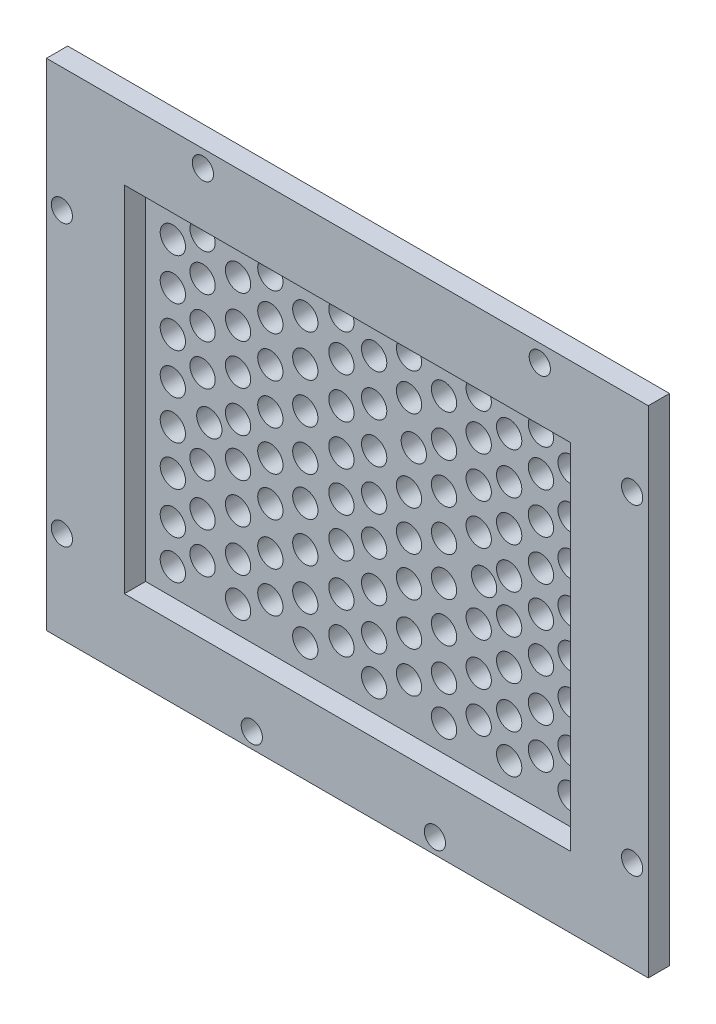
from build123d import *

# Parameters (mm, degrees)
SKETCH1_W                       = 85
SKETCH1_H                       = 70
BOSS_EXTRUDE1_DEPTH             = 6
SKETCH2_W                       = 76
SKETCH2_H                       = 61
SKETCH2_W_2                     = 65
SKETCH2_H_2                     = 52.171052632
CUT_EXTRUDE1_DEPTH              = 5
SKETCH8_W                       = 63
SKETCH8_H                       = 50
CUT_EXTRUDE2_DEPTH              = 3
SKETCH19_W                      = 85
SKETCH19_H                      = 70
SKETCH19_W_2                    = 76
SKETCH19_H_2                    = 61
CUT_EXTRUDE3_DEPTH              = 3
F_9_64_0_14063_DIAMETER_HOLE3_D = 3.572002
F_3_0MM_DOWEL_HOLE1_D           = 3
F_3_0MM_DOWEL_HOLE1_DEPTH       = 3


with BuildPart() as part:
    # Sketch1 → Boss-Extrude1 (new body)
    with BuildSketch(Plane.XY):
        Rectangle(SKETCH1_W, SKETCH1_H)
    extrude(amount=BOSS_EXTRUDE1_DEPTH)

    # Sketch2 → Cut-Extrude1 (cut)
    with BuildSketch(Plane(origin=(0, 0, 0), x_dir=(-1, 0, 0), z_dir=(0, 0, -1))):
        Rectangle(SKETCH2_W, SKETCH2_H)
        Rectangle(SKETCH2_W_2, SKETCH2_H_2, mode=Mode.SUBTRACT)
    extrude(amount=-CUT_EXTRUDE1_DEPTH, mode=Mode.SUBTRACT)

    # Sketch8 → Cut-Extrude2 (cut)
    with BuildSketch(Plane.XY.offset(6)):
        Rectangle(SKETCH8_W, SKETCH8_H)
    extrude(amount=-CUT_EXTRUDE2_DEPTH, mode=Mode.SUBTRACT)

    # Sketch19 → Cut-Extrude3 (cut)
    with BuildSketch(Plane(origin=(0, 0, 0), x_dir=(-1, 0, 0), z_dir=(0, 0, -1))):
        Rectangle(SKETCH19_W, SKETCH19_H)
        Rectangle(SKETCH19_W_2, SKETCH19_H_2, mode=Mode.SUBTRACT)
    extrude(amount=-CUT_EXTRUDE3_DEPTH, mode=Mode.SUBTRACT)

    # 9/64 (0.14063) Diameter Hole3 (through all)
    with Locations(Plane.XY.offset(3)):
        with Locations((28.529940603, -21.250215539), (28.529940603, -15.745880775), (28.529940603, -9.835912277), (28.529940603, -4.156518145), (28.529940603, 1.34781662), (28.529940603, 7.134244498), (28.529940603, 12.867155503), (28.529940603, 18.758619001), (24.333707157, 16.083468805), (24.333707157, 21.324215456), (24.333707157, 10.30729249), (24.333707157, 4.547623048), (24.333707157, -1.088505773), (24.333707157, -6.681369284), (24.333707157, -12.70462684), (24.333707157, -18.437537845), (19.848506548, -21.250215539), (19.848506548, -15.745880775), (19.848506548, -9.835912277), (19.848506548, -4.156518145), (19.848506548, 1.34781662), (19.848506548, 7.134244498), (19.848506548, 12.867155503), (19.848506548, 18.758619001), (15.547544477, 21.324215456), (15.547544477, 16.083468805), (15.547544477, 10.30729249), (15.547544477, 4.547623048), (16.308011503, -1.088505773), (15.547544477, -6.681369284), (15.547544477, -12.70462684), (15.547544477, -18.437537845), (10.648529587, -21.250215539), (10.648529587, -15.745880775), (10.648529587, -9.835912277), (10.648529587, -4.156518145), (10.648529587, 1.34781662), (10.648529587, 7.134244498), (10.648529587, 12.867155503), (10.648529587, 18.758619001), (5.705552369, 21.324215456), (5.705552369, 16.083468805), (6.382139513, 10.30729249), (5.705552369, 4.547623048), (5.705552369, -1.088505773), (5.705552369, -6.681369284), (5.705552369, -12.70462684), (5.705552369, -18.437537845), (0.781883537, -21.250215539), (0.781883537, -15.745880775), (0.781883537, -9.835912277), (0.781883537, -4.156518145), (0.781883537, 1.34781662), (0.781883537, 7.134244498), (0.781883537, 12.867155503), (0.781883537, 18.758619001), (-3.844195099, 21.324215456), (-3.844195099, 16.083468805), (-3.844195099, 10.30729249), (-3.844195099, 4.547623048), (-3.844195099, -1.088505773), (-3.844195099, -6.681369284), (-3.844195099, -12.70462684), (-3.844195099, -18.437537845), (-8.944854311, -21.250215539), (-8.944854311, -15.745880775), (-8.944854311, -9.835912277), (-8.944854311, -4.156518145), (-8.944854311, 1.34781662), (-8.944854311, 7.134244498), (-8.944854311, 12.867155503), (-8.944854311, 18.758619001), (-13.879613549, 21.324215456), (-13.879613549, 16.083468805), (-13.879613549, 10.30729249), (-13.879613549, 4.547623048), (-13.879613549, -1.088505773), (-13.879613549, -6.681369284), (-13.879613549, -12.70462684), (-13.879613549, -18.437537845), (-18.443188767, -21.250215539), (-18.443188767, -15.745880775), (-18.443188767, -9.835912277), (-18.443188767, -4.156518145), (-18.443188767, 1.34781662), (-18.443188767, 7.134244498), (-18.443188767, 12.867155503), (-18.443188767, 18.758619001), (-23.456120087, 21.324215456), (-23.456120087, 16.083468805), (-23.456120087, 10.30729249), (-23.456120087, 4.547623048), (-22.502226718, -1.088505773), (-23.456120087, -6.681369284), (-23.456120087, -12.70462684), (-23.456120087, -18.437537845), (-27.651383709, -21.250215539), (-27.651383709, -15.745880775), (-27.651383709, -9.835912277), (-27.651383709, -4.156518145), (-27.651383709, 1.34781662), (-27.651383709, 7.134244498), (-27.651383709, 12.867155503), (-27.651383709, 18.758619001)):
            Hole(F_9_64_0_14063_DIAMETER_HOLE3_D / 2)

    # Ø3.0mm Dowel Hole1
    with Locations(Plane(origin=(0, 0, 3), x_dir=(-1, 0, 0), z_dir=(0, 0, -1))):
        with Locations((13.498913812, -32.845700562), (-12.363328063, -32.845700562), (40.325591259, -22.041000365), (40.325591259, 17.495913013), (20.409683685, 32.588930896), (-27.176681905, 32.588930896), (-40.217959294, 23.331440204), (-40.217959294, -22.041000365)):
            Hole(F_3_0MM_DOWEL_HOLE1_D / 2, depth=F_3_0MM_DOWEL_HOLE1_DEPTH)


solid = part.part
